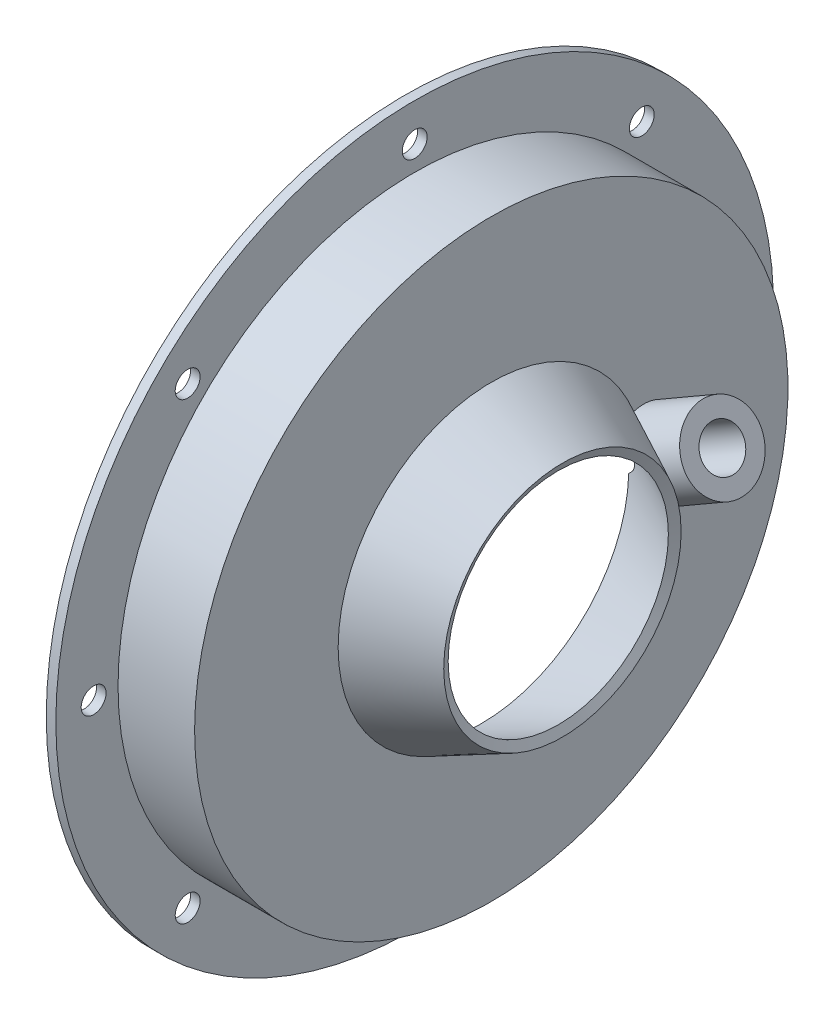
from build123d import *

# Parameters (mm, degrees)
SKETCH2_R                       = 3.302
CUT_EXTRUDE1_DEPTH              = 2.54
BOSS_EXTRUDE1_REACH             = 85.185
SKETCH3_R                       = 10.16
SKETCH3_R_2                     = 5.55625
BOSS_EXTRUDE1_DIRECTION_2_DEPTH = 10.16
CUT_EXTRUDE2_REACH              = 85.185
SKETCH3_7_R                     = 3.175


with BuildPart() as part:
    # Sketch1 → Revolve1 (revolve)
    with BuildSketch(Plane.XY):
        Polygon((0, 95.25), (2.54, 95.25), (2.54, 78.74), (22.86, 78.74), (22.86, 40.64), (41.745574265, 31.509467488), (40.64, 29.2227), (20.32, 39.046728544), (20.32, 76.2), (0, 76.2), align=None)
    revolve(axis=Axis((0, 0, 0), (1, 0, 0)))

    # Sketch2 → Cut-Extrude1 (cut)
    with BuildSketch(Plane(origin=(2.54, 0, 0), x_dir=(0, 0, -1), z_dir=(1, 0, 0))):
        with Locations((0, 85.217)):
            Circle(SKETCH2_R)
        with Locations((60.257518572, 60.257518572)):
            Circle(SKETCH2_R)
        with Locations((85.217, 0)):
            Circle(SKETCH2_R)
        with Locations((60.257518572, -60.257518572)):
            Circle(SKETCH2_R)
        with Locations((0, -85.217)):
            Circle(SKETCH2_R)
        with Locations((-60.257518572, -60.257518572)):
            Circle(SKETCH2_R)
        with Locations((-85.217, 0)):
            Circle(SKETCH2_R)
        with Locations((-60.257518572, 60.257518572)):
            Circle(SKETCH2_R)
    extrude(amount=-CUT_EXTRUDE1_DEPTH, mode=Mode.SUBTRACT)

    # Sketch3 → Boss-Extrude1 (add, up to next)
    with BuildSketch(Plane(origin=(30.795863359, 17.78, 0), x_dir=(0, 0, 1), z_dir=(0.866025404, 0.5, 0)), mode=Mode.PRIVATE) as boss_extrude1_sk1:
        with Locations((-40.474297606, 8.255)):
            Circle(SKETCH3_R)
        with Locations((-40.474297606, 8.255)):
            Circle(SKETCH3_R_2, mode=Mode.SUBTRACT)
    boss_extrude1_tool1 = extrude(boss_extrude1_sk1.sketch, amount=-BOSS_EXTRUDE1_REACH, mode=Mode.PRIVATE) - part.part
    add(boss_extrude1_tool1.solids().sort_by_distance((34.923363, 10.63096, -50.346929))[0])

    # Sketch3 → Boss-Extrude1 direction 2 (add)
    with BuildSketch(Plane(origin=(30.795863359, 17.78, 0), x_dir=(0, 0, 1), z_dir=(0.866025404, 0.5, 0))):
        with Locations((-40.474297606, 8.255)):
            Circle(SKETCH3_R)
        with Locations((-40.474297606, 8.255)):
            Circle(SKETCH3_R_2, mode=Mode.SUBTRACT)
    extrude(amount=BOSS_EXTRUDE1_DIRECTION_2_DEPTH)

    # Sketch3_7 → Cut-Extrude2 (cut, up to next)
    with BuildSketch(Plane(origin=(30.795863359, 17.78, 0), x_dir=(0, 0, 1), z_dir=(0.866025404, 0.5, 0)), mode=Mode.PRIVATE) as cut_extrude2_sk1:
        with Locations((-40.474297606, 8.255)):
            Circle(SKETCH3_7_R)
    cut_extrude2_tool1 = extrude(cut_extrude2_sk1.sketch, amount=-CUT_EXTRUDE2_REACH, mode=Mode.PRIVATE) & part.part
    add(cut_extrude2_tool1.solids().sort_by_distance((34.923363, 10.63096, -40.474298))[0], mode=Mode.SUBTRACT)


solid = part.part
